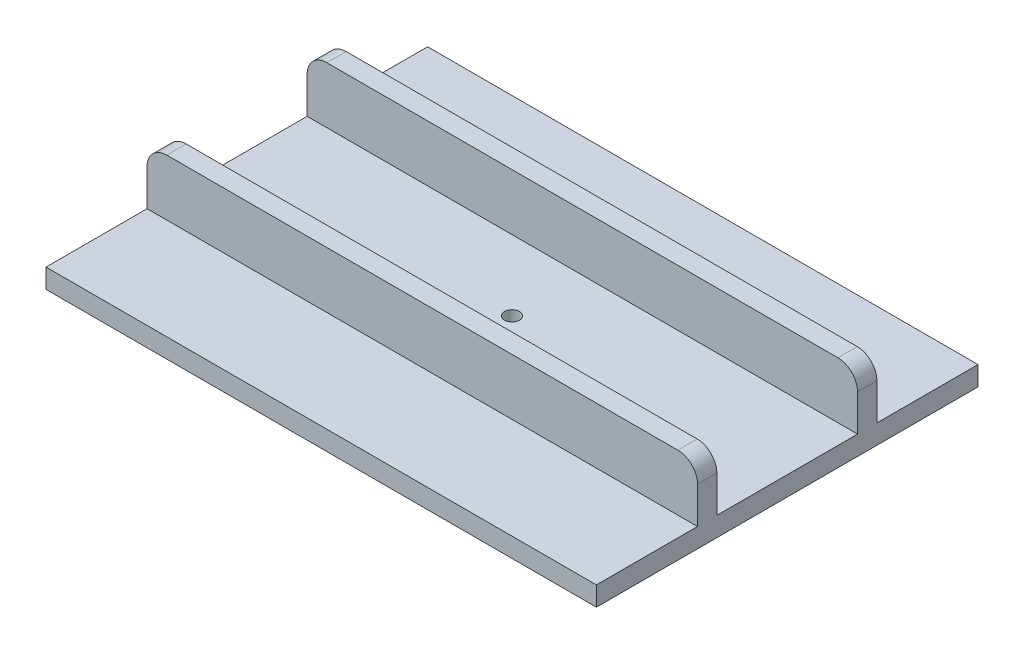
from build123d import *

# Parameters (mm, degrees)
SKETCH1_W           = 496.824
SKETCH1_H           = 344.424
BOSS_EXTRUDE1_DEPTH = 17.4625
CUT_EXTRUDE1_REACH  = 19.462
SKETCH3_R           = 6.76275
SKETCH5_W           = 496.824
SKETCH5_H           = 17.4625
BOSS_EXTRUDE2_DEPTH = 50.8
FILLET2_R           = 17.78


with BuildPart() as part:
    # Sketch1 → Boss-Extrude1 (new body)
    with BuildSketch(Plane(origin=(0, 0, 0), x_dir=(1, 0, 0), z_dir=(0, 1, 0))):
        Rectangle(SKETCH1_W, SKETCH1_H)
    extrude(amount=BOSS_EXTRUDE1_DEPTH)

    # Sketch3 → Cut-Extrude1 (cut, up to next)
    with BuildSketch(Plane(origin=(0, 17.4625, 0), x_dir=(1, 0, 0), z_dir=(0, 1, 0)), mode=Mode.PRIVATE) as cut_extrude1_sk1:
        Circle(SKETCH3_R)
    cut_extrude1_tool1 = extrude(cut_extrude1_sk1.sketch, amount=-CUT_EXTRUDE1_REACH, mode=Mode.PRIVATE) & part.part
    add(cut_extrude1_tool1.solids().sort_by_distance((0, 17.4625, 0))[0], mode=Mode.SUBTRACT)

    # Sketch5 → Boss-Extrude2 (add)
    with BuildSketch(Plane(origin=(0, 17.4625, 0), x_dir=(1, 0, 0), z_dir=(0, 1, 0))):
        with Locations((0, 72.23125)):
            Rectangle(SKETCH5_W, SKETCH5_H)
    boss_extrude2 = extrude(amount=BOSS_EXTRUDE2_DEPTH)

    # Mirror1: Boss-Extrude2 across plane
    add(boss_extrude2.mirror(Plane.XY))

    # Fillet2
    fillet2_edges = [part.edges().sort_by_distance(p)[0] for p in [
        (-248.412, 68.2625, -72.23125),
        (248.412, 68.2625, -72.23125),
        (-248.412, 68.2625, 72.23125),
        (248.412, 68.2625, 72.23125),
    ]]
    fillet(fillet2_edges, radius=FILLET2_R)


solid = part.part
